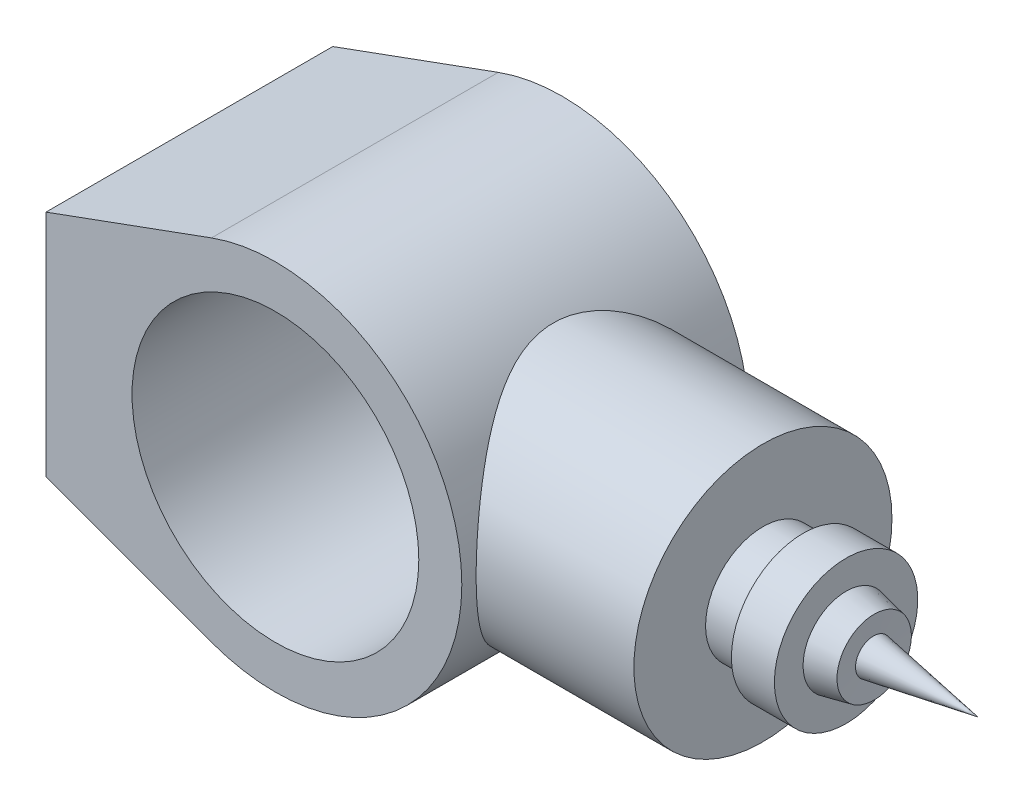
from build123d import *

# Parameters (mm, degrees)
SKETCH1_R           = 50
BOSS_EXTRUDE1_DEPTH = 50
BOSS_EXTRUDE2_REACH = 202
SKETCH2_R           = 45


with BuildPart() as part:
    # Sketch1 → Boss-Extrude1 (new body, symmetric)
    with BuildSketch(Plane.XY):
        with BuildLine():
            Line((-80, 40), (-80, -40))
            Line((-80, -40), (-22.281665693, -61.061668614))
            ThreePointArc((-22.281665693, -61.061668614), (65, 0), (-22.281665693, 61.061668614))
            Line((-22.281665693, 61.061668614), (-80, 40))
        make_face()
        Circle(SKETCH1_R, mode=Mode.SUBTRACT)
    extrude(amount=BOSS_EXTRUDE1_DEPTH, both=True)

    # Sketch2 → Boss-Extrude2 (add, up to next)
    with BuildSketch(Plane(origin=(120, 0, 0), x_dir=(0, 0, -1), z_dir=(1, 0, 0)), mode=Mode.PRIVATE) as boss_extrude2_sk1:
        Circle(SKETCH2_R)
    boss_extrude2_tool1 = extrude(boss_extrude2_sk1.sketch, amount=-BOSS_EXTRUDE2_REACH, mode=Mode.PRIVATE) - part.part
    add(boss_extrude2_tool1.solids().sort_by_distance((120, 0, 0))[0])

    # Sketch4 → Revolve1 (revolve)
    with BuildSketch(Plane.XY):
        Polygon((120, -20), (134, -20), (134, -25), (149, -25), (149, -15), (158.789932038, -12.961071192), (158.529899955, -6.239535459), (195, 0), (120, 0), align=None)
    revolve(axis=Axis((120, 0, 0), (1, 0, 0)))


solid = part.part
